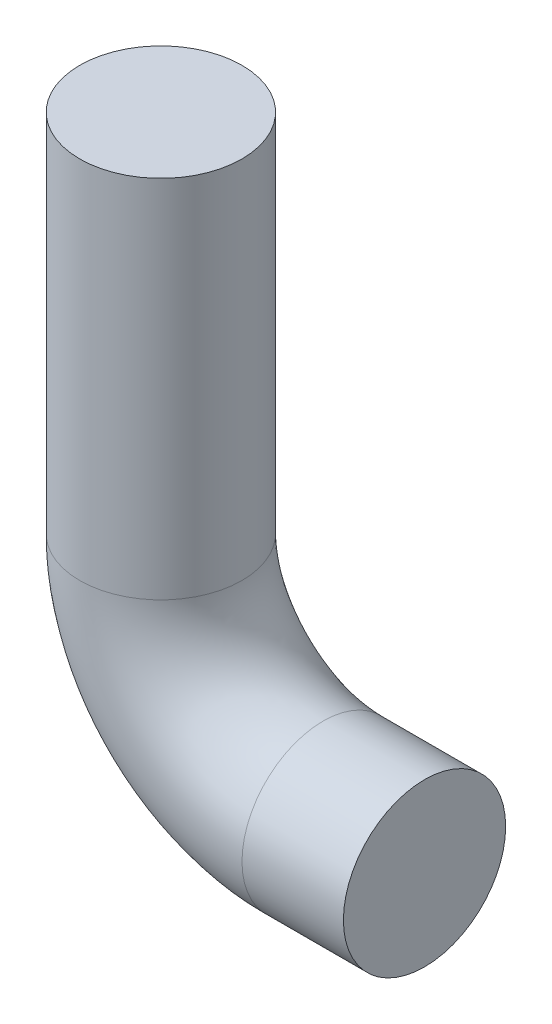
from build123d import *

# Parameters (mm, degrees)
SKETCH8_R = 25.4


with BuildPart() as part:
    # Sweep1: sweep along a path in Sketch7
    with BuildLine(Plane.XY) as sweep1_path:
        Line((0, 0), (-31.75, 0))
        ThreePointArc((-31.75, 0), (-67.671024484, 14.878975516), (-82.55, 50.8))
        Line((-82.55, 50.8), (-82.55, 165.1))
    # Sketch8 → Sweep1 (sweep)
    with BuildSketch(Plane(origin=(0, 0, 0), x_dir=(0, 0, -1), z_dir=(1, 0, 0))):
        Circle(SKETCH8_R)
    sweep(path=sweep1_path.line)


solid = part.part
